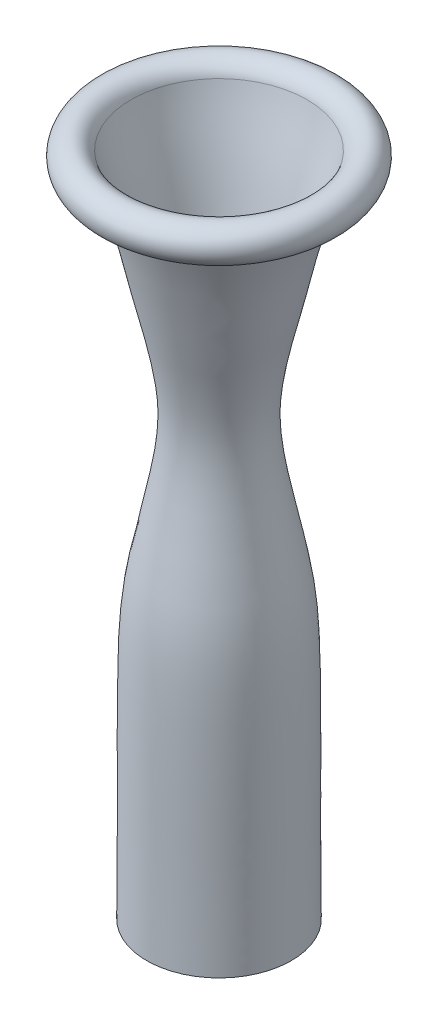
from build123d import *

# Parameters (mm, degrees)
SKETCH3_W               = 165.1
SKETCH3_H               = 366.624235
SKETCH3_W_2             = 152.4
SKETCH3_H_2             = 353.924235
CUT_EXTRUDE2_DEPTH      = 50.8
CUT_EXTRUDE2_DEPTH_BACK = 50.8


with BuildPart() as part:
    # Sketch1 → Revolve2 (revolve)
    with BuildSketch(Plane.XY):
        with BuildLine():
            add(Edge.make_bspline(
                [(37.774009, -0.24884), (37.725737, 7.239527), (37.620756, 22.220117), (37.519382, 44.667894), (37.58385, 67.126525), (37.585922, 89.612477), (37.419026, 112.079379), (37.041114, 130.966623), (35.85629, 146.084293), (34.305984, 157.422431), (32.108749, 168.557667), (29.80452, 179.539377), (27.4831, 190.5317), (25.261143, 201.553895), (23.479343, 212.548183), (22.441628, 223.502828), (22.4953, 234.340831), (23.785266, 245.269466), (25.737228, 256.224437), (28.159134, 267.043202), (30.887976, 277.957964), (34.223095, 292.659748), (37.390913, 307.221151), (41.382755, 321.46797), (44.418479, 331.152733), (46.312446, 337.350798), (47.069115, 339.963417)],
                knots=[-0.000749, -0.000749, -0.000749, -0.000749, 0.061949, 0.124648, 0.187346, 0.250044, 0.312743, 0.375441, 0.40679, 0.438139, 0.469488, 0.500838, 0.532187, 0.563536, 0.594885, 0.626234, 0.657584, 0.688933, 0.720282, 0.751631, 0.78298, 0.814329, 0.877028, 0.908377, 0.939726, 0.962258, 0.962258, 0.962258, 0.962258], degree=3))
            add(Edge.make_bspline(
                [(47.069115, 339.963417), (47.199909, 340.415022), (47.329647, 340.867246), (47.45817, 341.320129)],
                knots=[0.962258, 0.962258, 0.962258, 0.962258, 0.966153, 0.966153, 0.966153, 0.966153], degree=3))
            add(Edge.make_bspline(
                [(47.45817, 341.320129), (47.620616, 341.892552), (48.129769, 343.711734), (48.616128, 345.54229), (48.935473, 346.803389)],
                knots=[0.966153, 0.966153, 0.966153, 0.966153, 0.971075, 0.981768, 0.981768, 0.981768, 0.981768], degree=3))
            Line((48.935473, 346.803389), (47.95056, 347.052797))
            add(Edge.make_bspline(
                [(36.761324, -0.767406), (36.713132, 6.742248), (36.607676, 21.764243), (36.503616, 44.281116), (36.566526, 66.807518), (36.571495, 89.346333), (36.404461, 111.875329), (36.032478, 130.778359), (34.856117, 145.877218), (33.317616, 157.176324), (31.122622, 168.310453), (28.812167, 179.32121), (26.484122, 190.344776), (24.251863, 201.420132), (22.459803, 212.498604), (21.418048, 223.563539), (21.488357, 234.555684), (22.808146, 245.603491), (24.780916, 256.628156), (27.230092, 267.520785), (29.965585, 278.465305), (33.294501, 293.178805), (36.483809, 307.803061), (40.525403, 322.143444), (43.89485, 332.87388), (46.412835, 341.186323), (47.671542, 345.951008), (47.95056, 347.052797)],
                knots=[-0.002178, -0.002178, -0.002178, -0.002178, 0.060696, 0.12357, 0.186444, 0.249318, 0.312191, 0.375065, 0.406502, 0.437939, 0.469376, 0.500813, 0.53225, 0.563687, 0.595124, 0.626561, 0.657998, 0.689435, 0.720872, 0.752309, 0.783745, 0.815182, 0.878056, 0.909493, 0.94093, 0.972367, 0.981768, 0.981768, 0.981768, 0.981768], degree=3))
            Line((36.761324, -0.767406), (37.774009, -0.24884))
        make_face()
        with BuildLine():
            add(Edge.make_bspline(
                [(34.740559, -2.54), (34.735224, -1.693322), (34.687714, 5.737165), (34.57342, 22.109242), (34.45363, 48.031671), (34.585696, 78.15547), (34.401955, 113.788179), (33.757913, 144.512575), (28.583836, 170.714811), (23.069355, 196.377519), (17.851995, 223.661322), (21.083141, 248.143841), (24.280963, 264.247188), (29.775577, 285.705093), (34.111888, 307.612397), (40.255205, 328.200692), (43.62194, 338.76879), (45.421344, 345.371749), (45.830722, 346.964071)],
                knots=[-0.007088, -0.007088, -0.007088, -0.007088, 0, 0.055115, 0.129982, 0.217029, 0.307234, 0.428601, 0.473064, 0.530454, 0.648988, 0.70189, 0.736021, 0.786493, 0.887252, 0.922756, 0.966306, 0.980073, 0.980073, 0.980073, 0.980073], degree=3))
            Line((34.740559, -2.54), (35.756539, -2.533597))
            add(Edge.make_bspline(
                [(35.756539, -2.533597), (35.663568, 12.219405), (35.480054, 34.348921), (35.53667, 63.855621), (35.57038, 85.989378), (35.412296, 108.11258), (35.100919, 130.335445), (33.67511, 148.822056), (31.089455, 163.439954), (28.83395, 174.280309), (26.554614, 185.091112), (24.284554, 195.960523), (22.265629, 206.882983), (20.831965, 217.827759), (20.270269, 228.765528), (20.962264, 239.688525), (22.621298, 250.614307), (24.752945, 261.423393), (27.345668, 272.149062), (30.834497, 286.524624), (33.886576, 300.969768), (37.460905, 315.225365), (40.593706, 325.805915), (43.879531, 336.217427), (45.915642, 343.216841), (46.810075, 346.693006), (46.817529, 346.722006)],
                knots=[-0.007088, -0.007088, -0.007088, -0.007088, 0.116436, 0.178198, 0.239959, 0.301721, 0.363483, 0.425245, 0.456126, 0.487007, 0.517887, 0.548768, 0.579649, 0.61053, 0.641411, 0.672292, 0.703173, 0.734054, 0.764935, 0.795816, 0.857577, 0.888458, 0.919339, 0.95022, 0.979855, 0.980104, 0.980104, 0.980104, 0.980104], degree=3))
            ThreePointArc((46.817529, 346.722006), (46.858845, 346.891071), (46.90383, 347.059197))
            ThreePointArc((46.90383, 347.059197), (62.573935, 345.676477), (47.45817, 341.320129))
            add(Edge.make_bspline(
                [(47.069115, 339.963417), (47.199909, 340.415022), (47.329647, 340.867246), (47.45817, 341.320129)],
                knots=[0.962258, 0.962258, 0.962258, 0.962258, 0.966153, 0.966153, 0.966153, 0.966153], degree=3))
            ThreePointArc((47.069115, 339.963417), (63.519378, 346.296215), (45.922066, 347.320965))
            add(Edge.make_bspline(
                [(45.830722, 346.964071), (45.861299, 347.083), (45.891747, 347.201964), (45.922066, 347.320965)],
                knots=[0.980073, 0.980073, 0.980073, 0.980073, 0.981101, 0.981101, 0.981101, 0.981101], degree=3))
        make_face()
    revolve(axis=Axis((0, 0, 0), (0, 1, 0)))

    # Sketch3 → Cut-Extrude2 (cut, two sides)
    with BuildSketch(Plane.XY) as cut_extrude2_sk:
        with Locations((0, 176.962117)):
            Rectangle(SKETCH3_W, SKETCH3_H)
        with Locations((0, 176.962118)):
            Rectangle(SKETCH3_W_2, SKETCH3_H_2, mode=Mode.SUBTRACT)
    extrude(amount=CUT_EXTRUDE2_DEPTH, mode=Mode.SUBTRACT)
    extrude(cut_extrude2_sk.sketch, amount=-CUT_EXTRUDE2_DEPTH_BACK, mode=Mode.SUBTRACT)


solid = part.part
